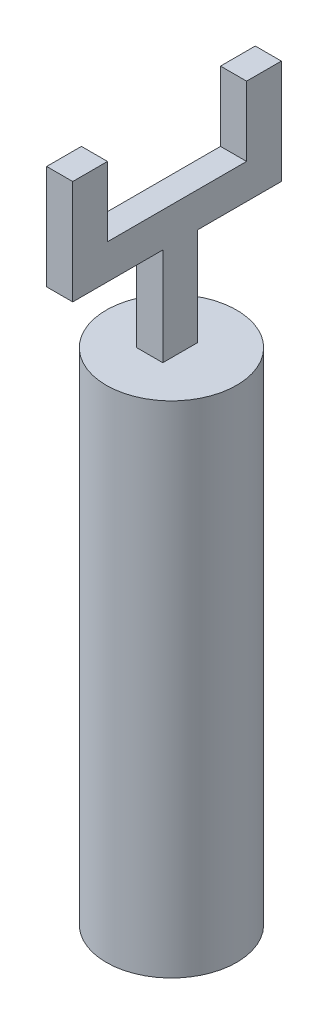
from build123d import *

# Parameters (mm, degrees)
SKETCH_1_R           = 0.75
EXTRUDE_1_DEPTH      = 5.75
EXTRUDE_3_DEPTH      = 0.1
EXTRUDE_3_DEPTH_BACK = 0.2


with BuildPart() as part:
    # 草图1 → 凸台-拉伸1 (new body)
    with BuildSketch(Plane(origin=(0, 0, 0), x_dir=(1, 0, 0), z_dir=(0, 1, 0))):
        Circle(SKETCH_1_R)
    extrude(amount=EXTRUDE_1_DEPTH)


with BuildPart() as body_2:
    # 草图2 → 凸台-拉伸3 (new body, two sides)
    with BuildSketch(Plane(origin=(0, 0, 0), x_dir=(0, 0, -1), z_dir=(1, 0, 0))) as extrude_3_sk:
        Polygon((-1.235982944, 8.073377801), (-1.235982944, 6.873377801), (-0.2, 6.873377801), (-0.2, 5.691937795), (0.2, 5.691937795), (0.2, 6.873377801), (1.164017056, 6.873377801), (1.164017056, 8.073377801), (0.764017056, 8.073377801), (0.764017056, 7.273377801), (-0.835982944, 7.273377801), (-0.835982944, 8.073377801), align=None)
    extrude(amount=EXTRUDE_3_DEPTH)
    extrude(extrude_3_sk.sketch, amount=-EXTRUDE_3_DEPTH_BACK)


solid = Compound([part.part, body_2.part])
